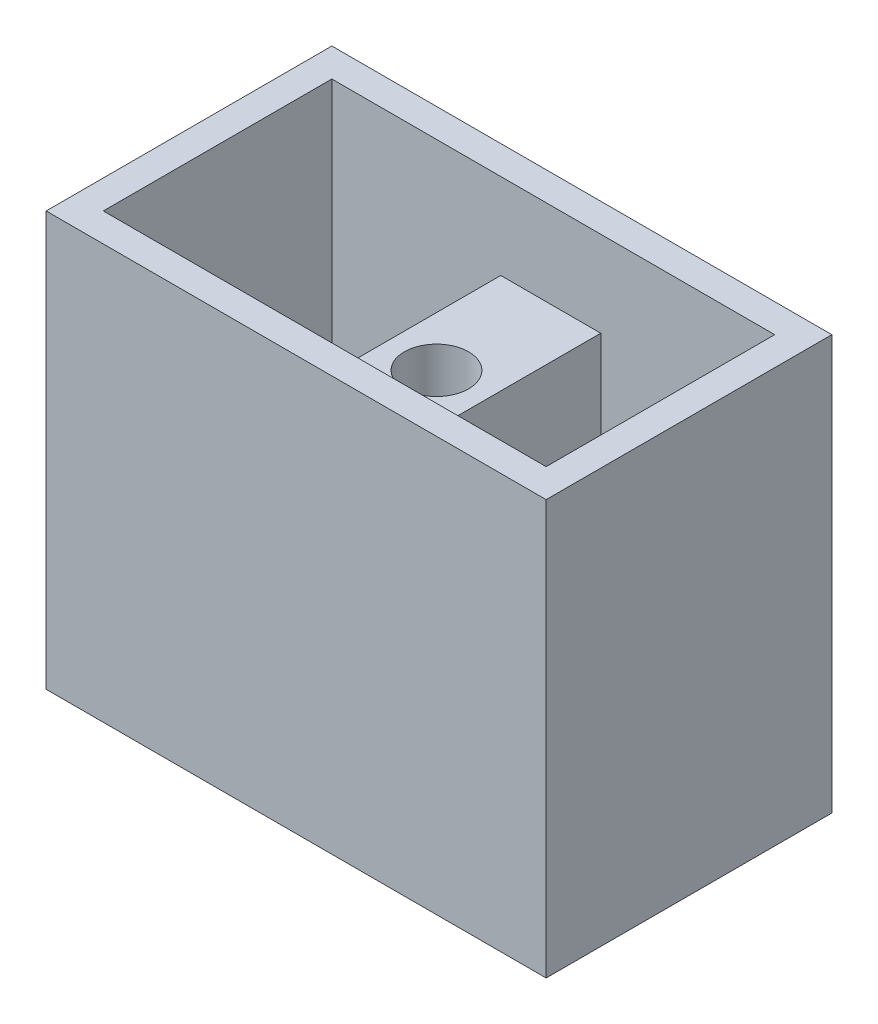
from build123d import *

# Parameters (mm, degrees)
SKETCH1_W           = 175
SKETCH1_H           = 100
BOSS_EXTRUDE1_DEPTH = 145
SKETCH2_R           = 11.25
SKETCH2_W           = 59.113281673
SKETCH2_H           = 80
SKETCH2_W_2         = 60.886718327
CUT_EXTRUDE1_DEPTH  = 145
SKETCH4_W           = 35
SKETCH4_H           = 80
CUT_EXTRUDE2_DEPTH  = 30
SKETCH5_W           = 35
SKETCH5_H           = 80
CUT_EXTRUDE3_DEPTH  = 30


with BuildPart() as part:
    # Sketch1 → Boss-Extrude1 (new body)
    with BuildSketch(Plane(origin=(0, 0, 0), x_dir=(1, 0, 0), z_dir=(0, 1, 0))):
        with Locations((87.5, 50)):
            Rectangle(SKETCH1_W, SKETCH1_H)
    extrude(amount=BOSS_EXTRUDE1_DEPTH)

    # Sketch2 → Cut-Extrude1 (cut)
    with BuildSketch(Plane(origin=(0, 145, 0), x_dir=(1, 0, 0), z_dir=(0, 1, 0))):
        with Locations((86.613281673, 50)):
            Circle(SKETCH2_R)
        with Locations((39.556640837, 50)):
            Rectangle(SKETCH2_W, SKETCH2_H)
        with Locations((134.556640837, 50)):
            Rectangle(SKETCH2_W_2, SKETCH2_H)
    extrude(amount=-CUT_EXTRUDE1_DEPTH, mode=Mode.SUBTRACT)

    # Sketch4 → Cut-Extrude2 (cut)
    with BuildSketch(Plane(origin=(0, 145, 0), x_dir=(1, 0, 0), z_dir=(0, 1, 0))):
        with Locations((86.613281673, 50)):
            Rectangle(SKETCH4_W, SKETCH4_H)
    extrude(amount=-CUT_EXTRUDE2_DEPTH, mode=Mode.SUBTRACT)

    # Sketch5 → Cut-Extrude3 (cut)
    with BuildSketch(Plane.XZ):
        with Locations((86.613281673, -50)):
            Rectangle(SKETCH5_W, SKETCH5_H)
    extrude(amount=-CUT_EXTRUDE3_DEPTH, mode=Mode.SUBTRACT)


solid = part.part
